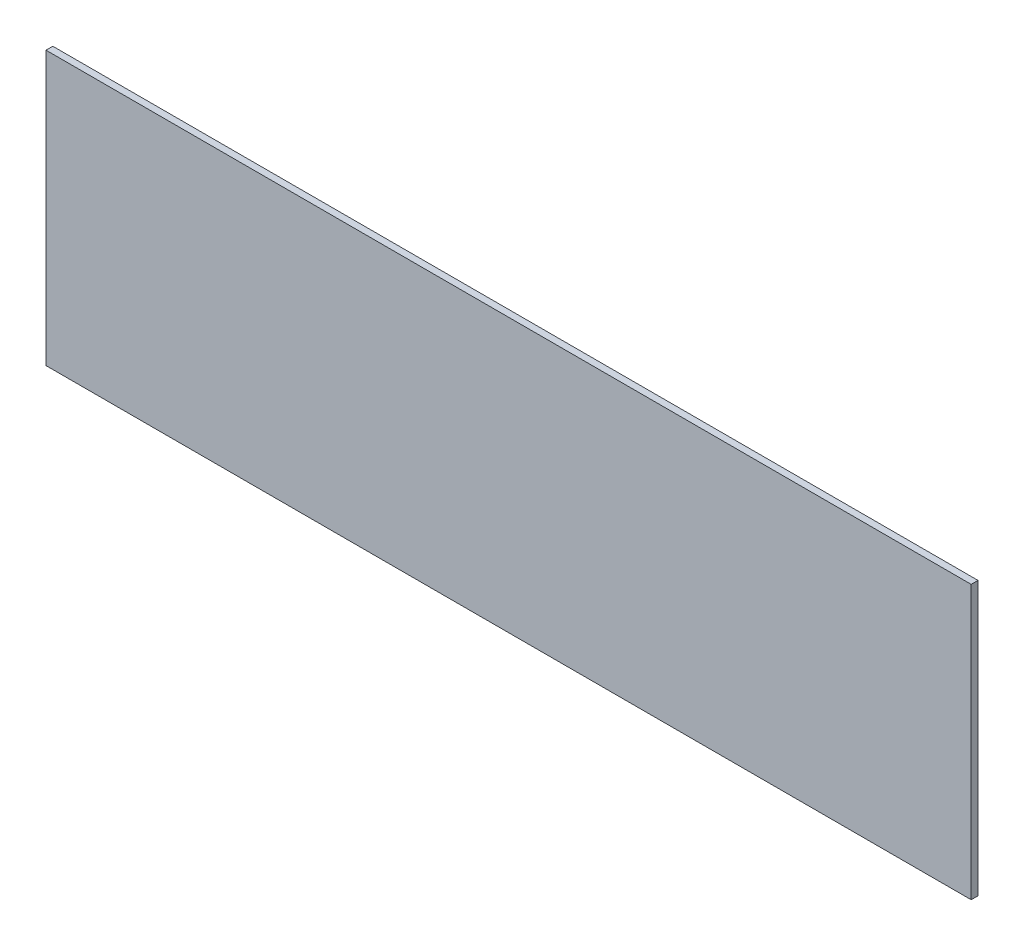
from build123d import *

# Parameters (mm, degrees)
SKETCH1_W           = 203.2
SKETCH1_H           = 60
BOSS_EXTRUDE1_DEPTH = 1.5


with BuildPart() as part:
    # Sketch1 → Boss-Extrude1 (new body)
    with BuildSketch(Plane.XY):
        Rectangle(SKETCH1_W, SKETCH1_H)
    extrude(amount=BOSS_EXTRUDE1_DEPTH)


solid = part.part
